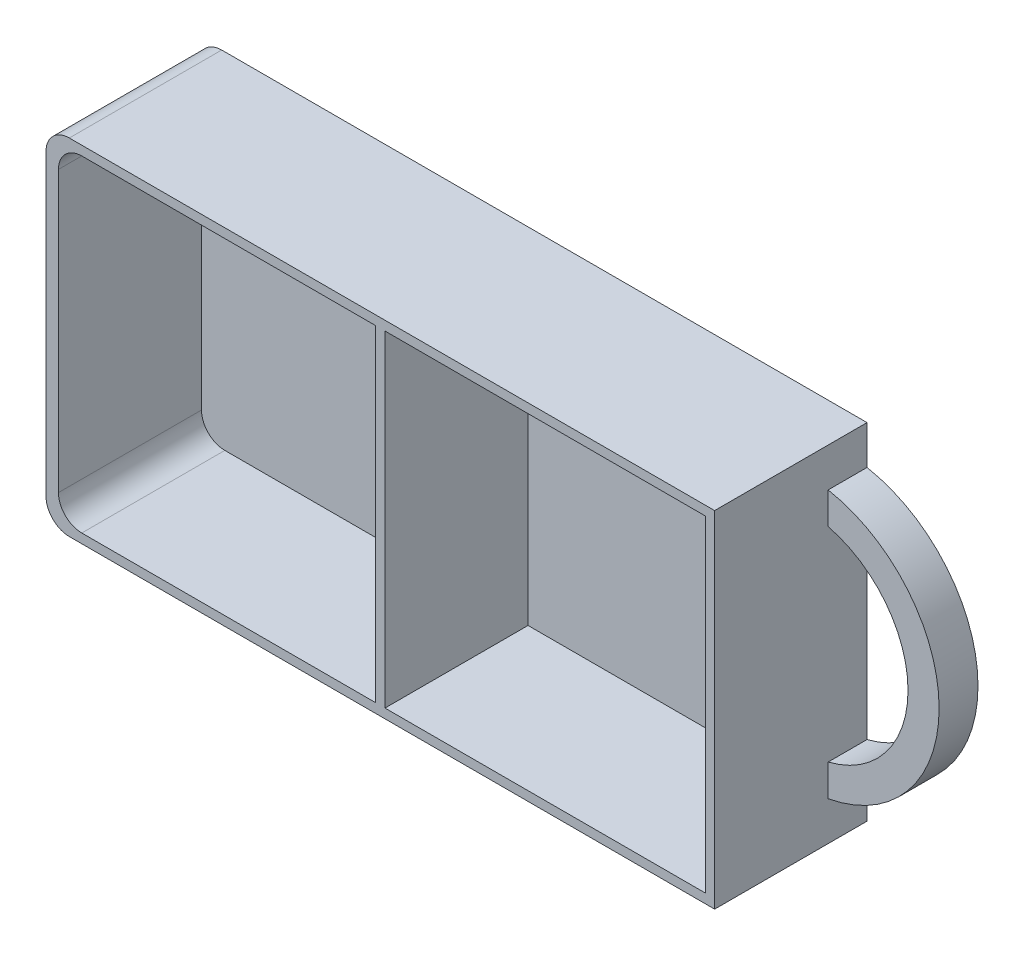
from build123d import *

# Parameters (mm, degrees)
SKETCH_1_W          = 86
SKETCH_1_H          = 44.4
EXTRUDE_1_DEPTH     = 19.6
EXTRUDE_2_DEPTH     = 5
SKETCH_3_W          = 40.8
SKETCH_3_H          = 42
SKETCH_3_W_2        = 41.2
CUT_EXTRUDE_1_DEPTH = 18.4
FILLET_1_R          = 3


with BuildPart() as part:
    # Эскиз1 → Бобышка-Вытянуть1 (new body)
    with BuildSketch(Plane.XY):
        Rectangle(SKETCH_1_W, SKETCH_1_H)
    extrude(amount=EXTRUDE_1_DEPTH)

    # Эскиз2 → Бобышка-Вытянуть2 (add)
    with BuildSketch(Plane.XY):
        with BuildLine():
            Line((43, 17.2), (43, 13.108775687))
            ThreePointArc((43, 13.108775687), (53.273546839, 0), (43, -13.108775687))
            Line((43, -13.108775687), (43, -17.2))
            ThreePointArc((43, -17.2), (57.273546839, 0), (43, 17.2))
        make_face()
    extrude(amount=EXTRUDE_2_DEPTH)

    # Эскиз3 → Вырез-Вытянуть1 (cut)
    with BuildSketch(Plane.XY.offset(19.6)):
        with Locations((-21, 0)):
            Rectangle(SKETCH_3_W, SKETCH_3_H)
        with Locations((21.2, 0)):
            Rectangle(SKETCH_3_W_2, SKETCH_3_H)
    extrude(amount=-CUT_EXTRUDE_1_DEPTH, mode=Mode.SUBTRACT)

    # Скругление1
    fillet_1_edges = [part.edges().sort_by_distance(p)[0] for p in [
        (-41.4, -21, 10.4),
        (-41.4, 21, 10.4),
        (-43, -22.2, 9.8),
        (-43, 22.2, 9.8),
    ]]
    fillet(fillet_1_edges, radius=FILLET_1_R)


solid = part.part
